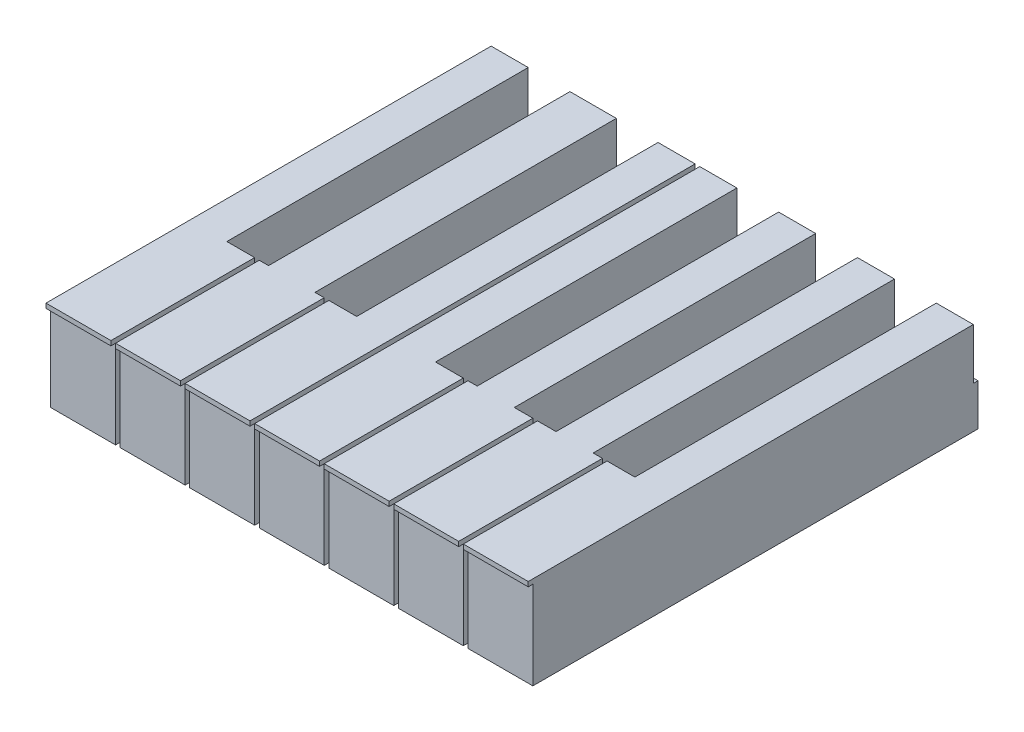
from build123d import *

# Parameters (mm, degrees)
BOSS_EXTRUDE1_DEPTH   = 31.75
BOSS_EXTRUDE1_2_DEPTH = 31.75
BOSS_EXTRUDE1_3_DEPTH = 31.75
BOSS_EXTRUDE1_4_DEPTH = 31.75
BOSS_EXTRUDE1_5_DEPTH = 31.75
BOSS_EXTRUDE1_6_DEPTH = 31.75
BOSS_EXTRUDE1_7_DEPTH = 31.75
SKETCH2_W             = 1.5875
SKETCH2_H             = 30.1625
CUT_EXTRUDE1_DEPTH    = 166.1
SKETCH4_W             = 1.5875
SKETCH4_H             = 14.2875
BOSS_EXTRUDE2_DEPTH   = 165.1


with BuildPart() as part:
    # Sketch1 → Boss-Extrude1 (new body)
    with BuildSketch(Plane(origin=(0, 0, 0), x_dir=(1, 0, 0), z_dir=(0, 1, 0))):
        Polygon((0, 0), (0, 152.4), (12.7, 152.4), (12.7, 49.2125), (22.225, 49.2125), (22.225, 0), align=None)
    extrude(amount=BOSS_EXTRUDE1_DEPTH)


with BuildPart() as body_2:
    # Sketch1 → Boss-Extrude1 2 (new body)
    with BuildSketch(Plane(origin=(0, 0, 0), x_dir=(1, 0, 0), z_dir=(0, 1, 0))):
        Polygon((23.8125, 49.2125), (26.9875, 49.2125), (26.9875, 152.4), (42.8625, 152.4), (42.8625, 49.2125), (46.0375, 49.2125), (46.0375, 0), (23.8125, 0), align=None)
    extrude(amount=BOSS_EXTRUDE1_2_DEPTH)


with BuildPart() as body_3:
    # Sketch1 → Boss-Extrude1 3 (new body)
    with BuildSketch(Plane(origin=(0, 0, 0), x_dir=(1, 0, 0), z_dir=(0, 1, 0))):
        Polygon((47.625, 49.2125), (57.15, 49.2125), (57.15, 152.4), (69.85, 152.4), (69.85, 0), (47.625, 0), align=None)
    extrude(amount=BOSS_EXTRUDE1_3_DEPTH)


with BuildPart() as body_4:
    # Sketch1 → Boss-Extrude1 4 (new body)
    with BuildSketch(Plane(origin=(0, 0, 0), x_dir=(1, 0, 0), z_dir=(0, 1, 0))):
        Polygon((71.4375, 152.4), (71.4375, 0), (93.6625, 0), (93.6625, 49.2125), (84.1375, 49.2125), (84.1375, 152.4), align=None)
    extrude(amount=BOSS_EXTRUDE1_4_DEPTH)


with BuildPart() as body_5:
    # Sketch1 → Boss-Extrude1 5 (new body)
    with BuildSketch(Plane(origin=(0, 0, 0), x_dir=(1, 0, 0), z_dir=(0, 1, 0))):
        Polygon((95.25, 0), (95.25, 49.2125), (98.425, 49.2125), (98.425, 152.4), (111.125, 152.4), (111.125, 49.2125), (117.475, 49.2125), (117.475, 0), align=None)
    extrude(amount=BOSS_EXTRUDE1_5_DEPTH)


with BuildPart() as body_6:
    # Sketch1 → Boss-Extrude1 6 (new body)
    with BuildSketch(Plane(origin=(0, 0, 0), x_dir=(1, 0, 0), z_dir=(0, 1, 0))):
        Polygon((119.0625, 49.2125), (125.4125, 49.2125), (125.4125, 152.4), (138.1125, 152.4), (138.1125, 49.2125), (141.2875, 49.2125), (141.2875, 0), (119.0625, 0), align=None)
    extrude(amount=BOSS_EXTRUDE1_6_DEPTH)


with BuildPart() as body_7:
    # Sketch1 → Boss-Extrude1 7 (new body)
    with BuildSketch(Plane(origin=(0, 0, 0), x_dir=(1, 0, 0), z_dir=(0, 1, 0))):
        Polygon((142.875, 49.2125), (152.4, 49.2125), (152.4, 152.4), (165.1, 152.4), (165.1, 0), (142.875, 0), align=None)
    extrude(amount=BOSS_EXTRUDE1_7_DEPTH)


with BuildPart() as cut_extrude1_tool:
    # Sketch2 → Cut-Extrude1 (new body, through all)
    with BuildSketch(Plane.ZY):
        with Locations((-0.79375, 15.08125)):
            Rectangle(SKETCH2_W, SKETCH2_H)
    extrude(amount=-CUT_EXTRUDE1_DEPTH)


with BuildPart() as part_1:
    add(part.part)

    # Cut-Extrude1: cut by cut_extrude1_tool
    add(cut_extrude1_tool.part, mode=Mode.SUBTRACT)



with BuildPart() as body_2_1:
    add(body_2.part)

    # Cut-Extrude1: cut by cut_extrude1_tool
    add(cut_extrude1_tool.part, mode=Mode.SUBTRACT)


with BuildPart() as body_3_1:
    add(body_3.part)

    # Cut-Extrude1: cut by cut_extrude1_tool
    add(cut_extrude1_tool.part, mode=Mode.SUBTRACT)


with BuildPart() as body_4_1:
    add(body_4.part)

    # Cut-Extrude1: cut by cut_extrude1_tool
    add(cut_extrude1_tool.part, mode=Mode.SUBTRACT)


with BuildPart() as body_5_1:
    add(body_5.part)

    # Cut-Extrude1: cut by cut_extrude1_tool
    add(cut_extrude1_tool.part, mode=Mode.SUBTRACT)


with BuildPart() as body_6_1:
    add(body_6.part)

    # Cut-Extrude1: cut by cut_extrude1_tool
    add(cut_extrude1_tool.part, mode=Mode.SUBTRACT)


with BuildPart() as body_7_1:
    add(body_7.part)

    # Cut-Extrude1: cut by cut_extrude1_tool
    add(cut_extrude1_tool.part, mode=Mode.SUBTRACT)


with BuildPart() as part_2:
    add(part_1.part)

    add(body_2_1.part)  # Boss-Extrude2 merges body 2

    add(body_3_1.part)  # Boss-Extrude2 merges body 3

    add(body_4_1.part)  # Boss-Extrude2 merges body 4

    add(body_5_1.part)  # Boss-Extrude2 merges body 5

    add(body_6_1.part)  # Boss-Extrude2 merges body 6

    add(body_7_1.part)  # Boss-Extrude2 merges body 7
    # Sketch4 → Boss-Extrude2 (add, through all)
    with BuildSketch(Plane(origin=(0, 0, 0), x_dir=(0, 0, -1), z_dir=(1, 0, 0))):
        with Locations((153.19375, 7.14375)):
            Rectangle(SKETCH4_W, SKETCH4_H)
    extrude(amount=BOSS_EXTRUDE2_DEPTH)


solid = part_2.part
